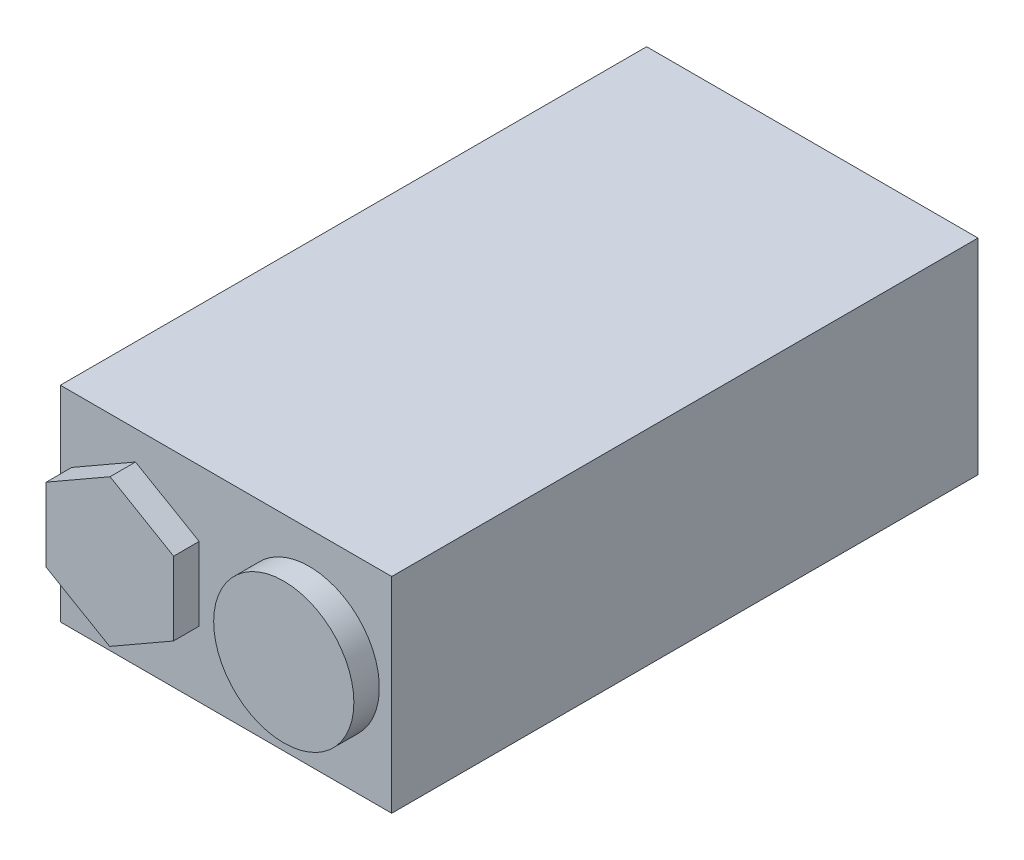
from build123d import *

# Parameters (mm, degrees)
SKETCH1_W           = 26
SKETCH1_H           = 16.09
BOSS_EXTRUDE1_DEPTH = 46
SKETCH2_R           = 5.5
BOSS_EXTRUDE2_DEPTH = 2


with BuildPart() as part:
    # Sketch1 → Boss-Extrude1 (new body)
    with BuildSketch(Plane.XY):
        Rectangle(SKETCH1_W, SKETCH1_H)
    extrude(amount=BOSS_EXTRUDE1_DEPTH)

    # Sketch2 → Boss-Extrude2 (add)
    with BuildSketch(Plane.XY.offset(46)):
        with Locations((6.529444473, 0)):
            Circle(SKETCH2_R)
        Polygon((-7.134758176, -5.773481444), (-2.126944774, -2.900305802), (-2.111281169, 2.873175642), (-7.103430965, 5.773481444), (-12.111244367, 2.900305802), (-12.126907972, -2.873175642), align=None)
    extrude(amount=BOSS_EXTRUDE2_DEPTH)


solid = part.part
